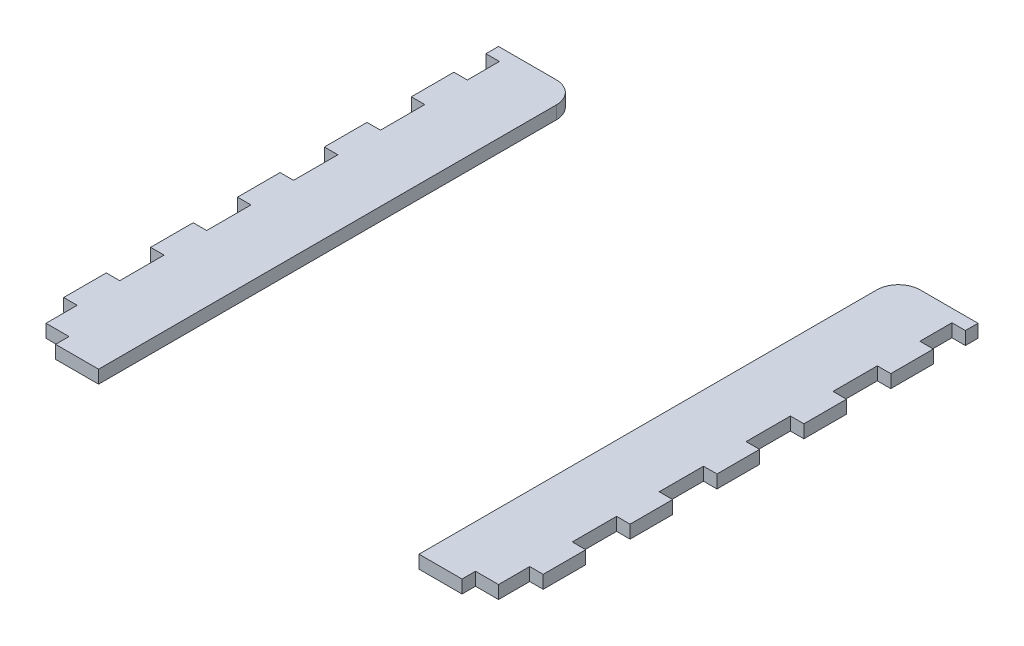
from build123d import *

# Parameters (mm, degrees)
BOSS_EXTRUDE1_DEPTH   = 3
BOSS_EXTRUDE1_2_DEPTH = 3
SKETCH2_W             = 3.2
SKETCH2_H             = 10.2
SKETCH2_H_2           = 7.372217102
CUT_EXTRUDE1_DEPTH    = 4


with BuildPart() as part:
    # Sketch1 → Boss-Extrude1 (new body)
    with BuildSketch(Plane(origin=(0, 0, 0), x_dir=(1, 0, 0), z_dir=(0, 1, 0))):
        with BuildLine():
            Line((-36.872217102, 38.501443346), (-36.872217102, -66.842990858))
            Line((-36.872217102, -66.842990858), (-55.172217102, -66.842990858))
            Line((-55.172217102, -66.842990858), (-55.172217102, 43.501443346))
            Line((-55.172217102, 43.501443346), (-41.872217102, 43.501443346))
            ThreePointArc((-41.872217102, 43.501443346), (-38.336683196, 42.036977252), (-36.872217102, 38.501443346))
        make_face()
    extrude(amount=-BOSS_EXTRUDE1_DEPTH)


with BuildPart() as body_2:
    # Sketch1 → Boss-Extrude1 2 (new body)
    with BuildSketch(Plane(origin=(0, 0, 0), x_dir=(1, 0, 0), z_dir=(0, 1, 0))):
        with BuildLine():
            Line((36.872217102, 38.501443346), (36.872217102, -66.842990858))
            Line((36.872217102, -66.842990858), (55.172217102, -66.842990858))
            Line((55.172217102, -66.842990858), (55.172217102, 43.501443346))
            Line((55.172217102, 43.501443346), (41.872217102, 43.501443346))
            ThreePointArc((41.872217102, 43.501443346), (38.336683196, 42.036977252), (36.872217102, 38.501443346))
        make_face()
    extrude(amount=-BOSS_EXTRUDE1_2_DEPTH)


with BuildPart() as cut_extrude1_tool:
    # Sketch2 → Cut-Extrude1 (new body, through all)
    with BuildSketch(Plane(origin=(0, 0, 0), x_dir=(1, 0, 0), z_dir=(0, 1, 0))):
        with Locations((53.672217102, -1.670773756)):
            Rectangle(SKETCH2_W, SKETCH2_H)
        with Locations((53.672217102, 18.329226244)):
            Rectangle(SKETCH2_W, SKETCH2_H)
        with Locations((53.672217102, -21.670773756)):
            Rectangle(SKETCH2_W, SKETCH2_H)
        with Locations((-53.672217102, 18.329226244)):
            Rectangle(SKETCH2_W, SKETCH2_H)
        with Locations((-53.672217102, -1.670773756)):
            Rectangle(SKETCH2_W, SKETCH2_H)
        with Locations((53.672217102, 36.915334795)):
            Rectangle(SKETCH2_W, SKETCH2_H_2)
        with Locations((-53.672217102, -21.670773756)):
            Rectangle(SKETCH2_W, SKETCH2_H)
        with Locations((53.672217102, -41.670773756)):
            Rectangle(SKETCH2_W, SKETCH2_H)
        Polygon((46.772217102, -66.942990858), (55.272217102, -66.942990858), (55.272217102, -56.570773756), (52.072217102, -56.570773756), (52.072217102, -63.742990858), (46.772217102, -63.742990858), align=None)
        with Locations((-53.672217102, 36.915334795)):
            Rectangle(SKETCH2_W, SKETCH2_H_2)
        with Locations((-53.672217102, -41.670773756)):
            Rectangle(SKETCH2_W, SKETCH2_H)
        Polygon((-46.772217102, -66.942990858), (-55.272217102, -66.942990858), (-55.272217102, -56.570773756), (-52.072217102, -56.570773756), (-52.072217102, -63.742990858), (-46.772217102, -63.742990858), align=None)
    extrude(amount=-CUT_EXTRUDE1_DEPTH)


with BuildPart() as part_1:
    add(part.part)

    # Cut-Extrude1: cut by cut_extrude1_tool
    add(cut_extrude1_tool.part, mode=Mode.SUBTRACT)


with BuildPart() as body_2_1:
    add(body_2.part)

    # Cut-Extrude1: cut by cut_extrude1_tool
    add(cut_extrude1_tool.part, mode=Mode.SUBTRACT)


solid = Compound([part_1.part, body_2_1.part])
